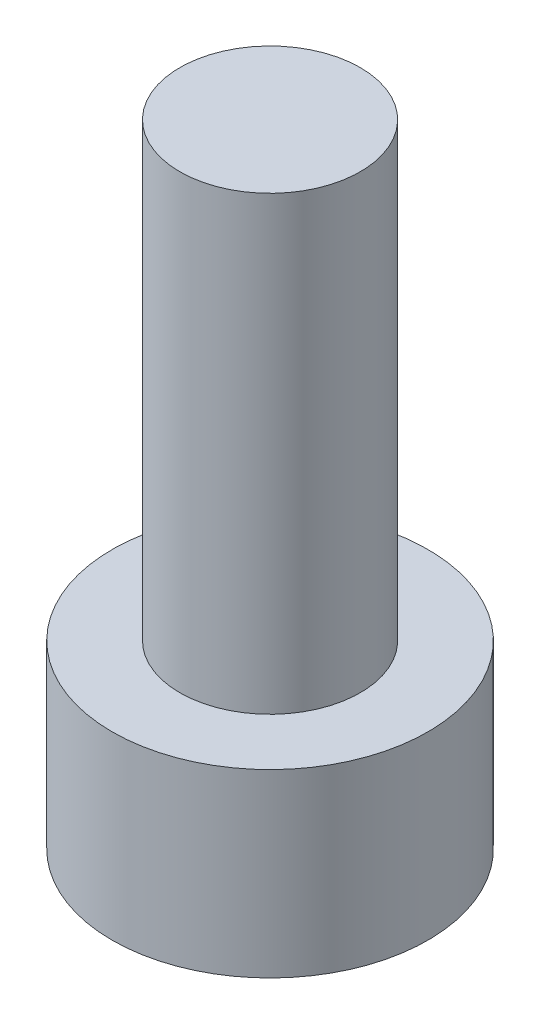
from build123d import *

# Parameters (mm, degrees)
SKETCH1_R           = 3.5
BOSS_EXTRUDE1_DEPTH = 4
SKETCH2_R           = 2
BOSS_EXTRUDE2_DEPTH = 10


with BuildPart() as part:
    # Sketch1 → Boss-Extrude1 (new body)
    with BuildSketch(Plane(origin=(0, 0, 0), x_dir=(1, 0, 0), z_dir=(0, 1, 0))):
        Circle(SKETCH1_R)
    extrude(amount=BOSS_EXTRUDE1_DEPTH)

    # Sketch2 → Boss-Extrude2 (add)
    with BuildSketch(Plane(origin=(0, 4, 0), x_dir=(1, 0, 0), z_dir=(0, 1, 0))):
        Circle(SKETCH2_R)
    extrude(amount=BOSS_EXTRUDE2_DEPTH)


solid = part.part
